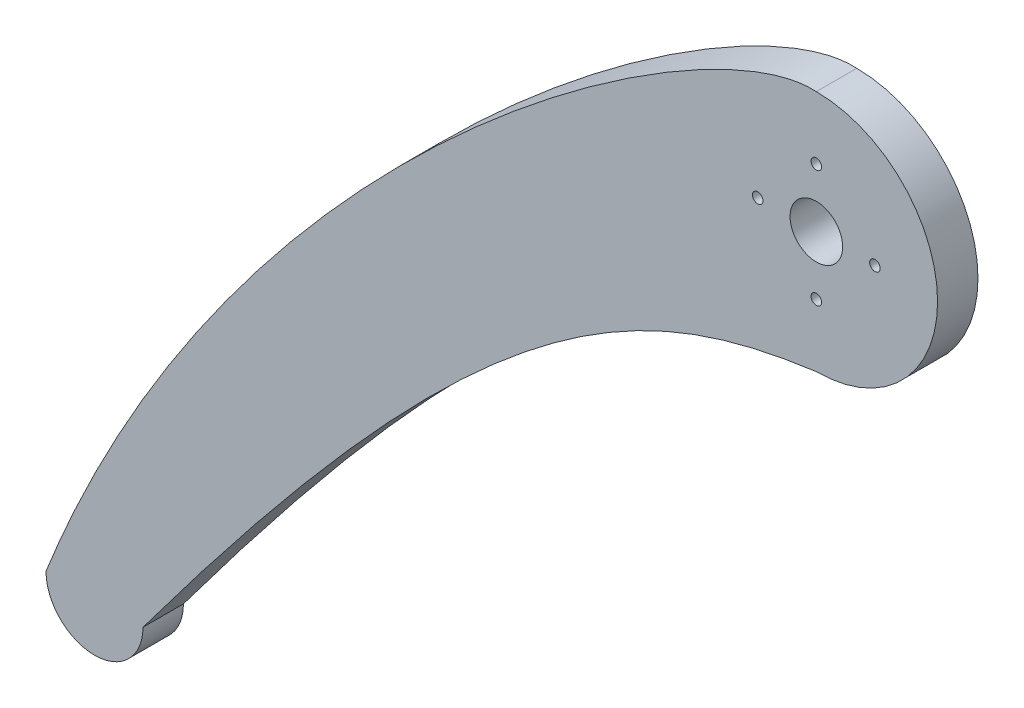
from build123d import *

# Parameters (mm, degrees)
BOSS_EXTRUDE1_DEPTH = 5
SKETCH2_R           = 3.25
SKETCH2_R_2         = 0.65
CUT_EXTRUDE1_DEPTH  = 5


with BuildPart() as part:
    # Sketch1 → Boss-Extrude1 (new body)
    with BuildSketch(Plane.XY):
        with BuildLine():
            ThreePointArc((0, -15), (15, 0), (0, 15))
            add(Edge.make_bspline(
                [(0, 15), (-14.230583968, 15.97401443), (-71.542634771, -23.896673221), (-95.29355487, -84.024349777)],
                knots=[0, 0, 0, 0, 1, 1, 1, 1], degree=3))
            ThreePointArc((-95.29355487, -84.024349777), (-89.29355487, -90.024349777), (-83.293554869, -84.024349777))
            add(Edge.make_bspline(
                [(0, -15), (-22.042025083, -17.979465659), (-40.938355496, -27.190384656), (-83.293554869, -84.024349777)],
                knots=[0, 0, 0, 0, 1, 1, 1, 1], degree=3))
        make_face()
    extrude(amount=BOSS_EXTRUDE1_DEPTH)

    # Sketch2 → Cut-Extrude1 (cut)
    with BuildSketch(Plane.XY.offset(5)):
        Circle(SKETCH2_R)
        with Locations((0, 7.25)):
            Circle(SKETCH2_R_2)
        with Locations((-7.25, 0)):
            Circle(SKETCH2_R_2)
        with Locations((0, -7.25)):
            Circle(SKETCH2_R_2)
        with Locations((7.25, 0)):
            Circle(SKETCH2_R_2)
    extrude(amount=-CUT_EXTRUDE1_DEPTH, mode=Mode.SUBTRACT)


solid = part.part
